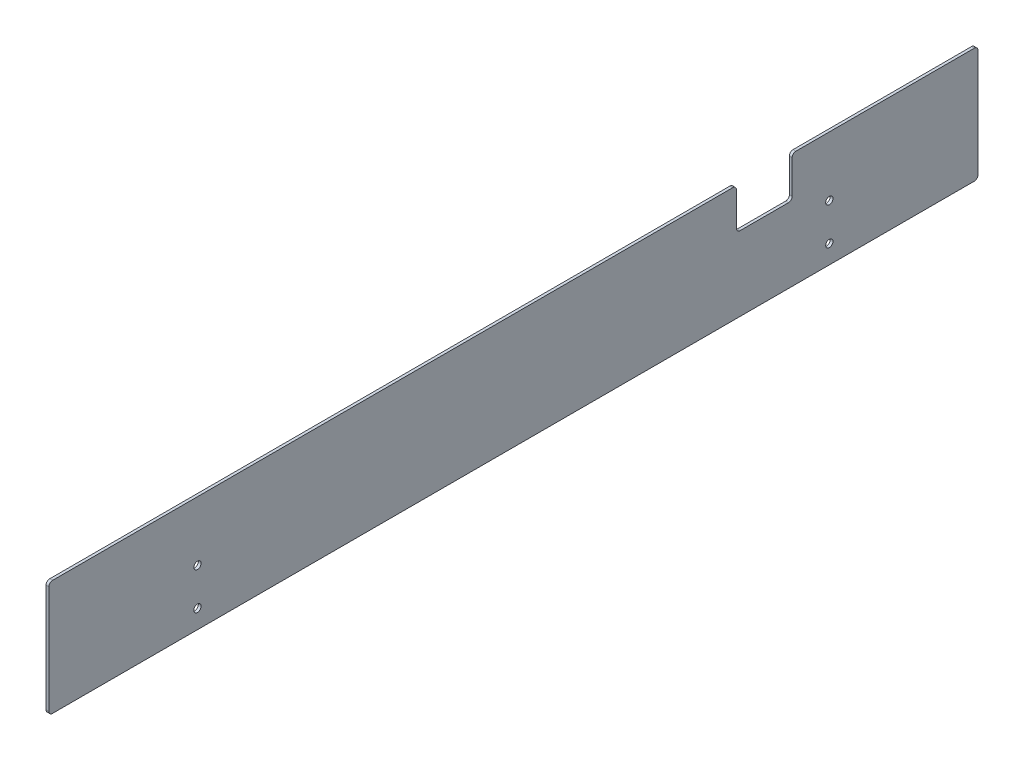
from build123d import *

# Parameters (mm, degrees)
BOSS_EXTRUDE1_DEPTH = 1.5
FILLET1_R           = 2
SKETCH2_R           = 1.95
CUT_EXTRUDE1_DEPTH  = 10


with BuildPart() as part:
    # Sketch1 → Boss-Extrude1 (new body)
    with BuildSketch(Plane(origin=(0, 0, 0), x_dir=(0, 0, -1), z_dir=(1, 0, 0))):
        Polygon((130.053191489, -78.292553191), (230.053191489, -78.292553191), (230.053191489, -140.292553191), (-269.946808511, -140.292553191), (-269.946808511, -78.292553191), (100.053191489, -78.292553191), (100.053191489, -100.292553191), (130.053191489, -100.292553191), align=None)
    extrude(amount=BOSS_EXTRUDE1_DEPTH)

    # Fillet1
    fillet1_edges = [part.edges().sort_by_distance(p)[0] for p in [
        (0.75, -78.292553191, 269.946808511),
        (0.75, -78.292553191, -100.053191489),
        (0.75, -100.292553191, -100.053191489),
        (0.75, -100.292553191, -130.053191489),
        (0.75, -78.292553191, -130.053191489),
        (0.75, -78.292553191, -230.053191489),
        (0.75, -140.292553191, -230.053191489),
        (0.75, -140.292553191, 269.946808511),
    ]]
    fillet(fillet1_edges, radius=FILLET1_R)

    # Sketch2 → Cut-Extrude1 (cut)
    with BuildSketch(Plane.ZY):
        with Locations((-150.053191489, -110.292553191)):
            Circle(SKETCH2_R)
        with Locations((-150.053191489, -130.292553191)):
            Circle(SKETCH2_R)
        with Locations((189.946808511, -110.292553191)):
            Circle(SKETCH2_R)
        with Locations((189.946808511, -130.292553191)):
            Circle(SKETCH2_R)
    extrude(amount=-CUT_EXTRUDE1_DEPTH, mode=Mode.SUBTRACT)


solid = part.part
